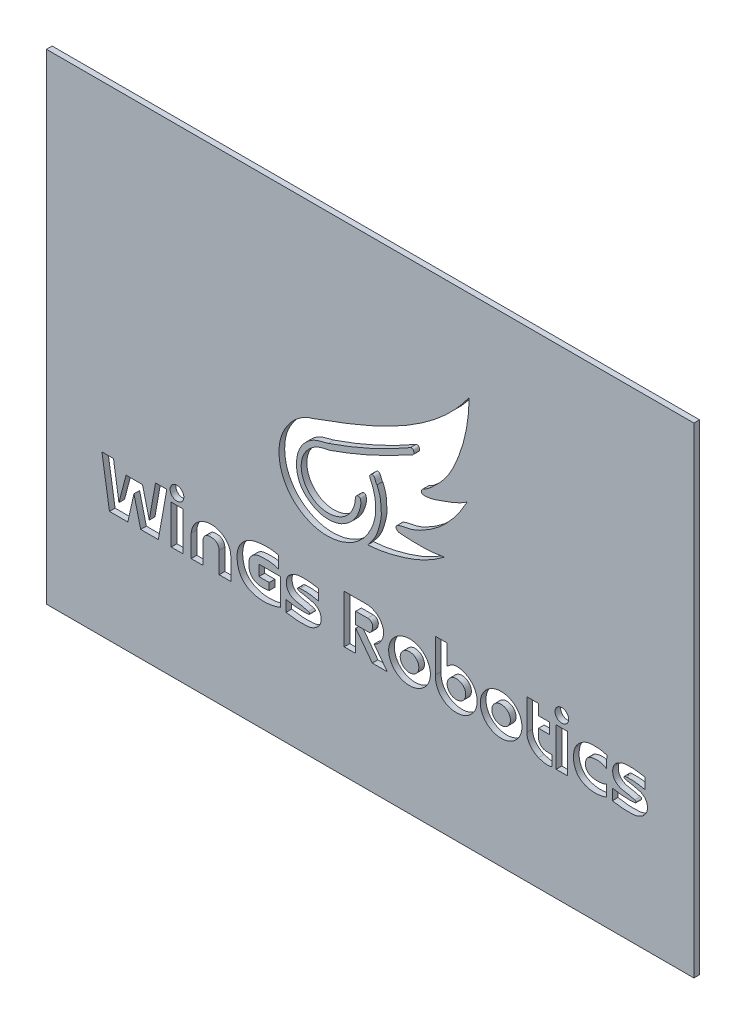
from build123d import *

# Parameters (mm, degrees)
SKETCH1_W           = 114.5
SKETCH1_H           = 85
BOSS_EXTRUDE1_DEPTH = 1
SKETCH2_W           = 2.050080953
SKETCH2_H           = 6.874434124
SKETCH2_R           = 1.213859124
SKETCH2_RX          = 3.688040456
SKETCH2_RY          = 3.586339088
SKETCH2_RX_2        = 1.645091786
SKETCH2_RY_2        = 1.613451305
SKETCH2_W_2         = 1.981029746
SKETCH2_H_2         = 6.809423223
SKETCH2_R_2         = 1.204225855
CUT_EXTRUDE1_DEPTH  = 11


with BuildPart() as part:
    # Sketch1 → Boss-Extrude1 (new body)
    with BuildSketch(Plane.XY):
        with Locations((57.25, 42.5)):
            Rectangle(SKETCH1_W, SKETCH1_H)
    extrude(amount=BOSS_EXTRUDE1_DEPTH)

    # Sketch2 → Cut-Extrude1 (cut)
    with BuildSketch(Plane.XY.offset(1)):
        with BuildLine():
            add(Edge.make_bspline(
                [(58.454232807, 47.516375152), (58.155201107, 47.766256761), (58.242612626, 48.405648514), (57.63435824, 48.725818852), (57.33951575, 48.561080563), (57.148056352, 48.331669293), (57.191833565, 47.968880637), (57.373109598, 47.594828313), (57.64633552, 47.047787141), (57.835821816, 46.438243828), (58.054855682, 45.66789616), (58.183227128, 44.904585404), (58.245836004, 43.851782874), (58.214820236, 42.740629424), (57.93171993, 41.583185887), (57.630830141, 40.625252894), (57.159571505, 39.759385244), (56.516222929, 38.60157538), (55.42470024, 37.436336943), (54.116750982, 36.463653396), (52.894350187, 35.923293203), (51.77243295, 35.514319825), (50.450751358, 35.31741506), (48.783731824, 35.237164884), (46.898690964, 35.69687239), (44.924093636, 36.617380122), (43.161708961, 38.106675964), (42.003804738, 39.901498444), (41.341001552, 41.702039563), (41.031458158, 43.795886426), (41.241639988, 46.031174435), (42.353202792, 48.424037338), (44.089054597, 50.650061335), (46.063860923, 51.731417101), (47.183080217, 52.026795225)],
                knots=[0, 0, 0, 0, 0.025484439, 0.03338283, 0.040232234, 0.046589479, 0.052344178, 0.063458754, 0.074883627, 0.093534169, 0.106469828, 0.129018368, 0.145624842, 0.177759685, 0.20359143, 0.225939601, 0.245354605, 0.270053463, 0.315285484, 0.351906237, 0.379454707, 0.405318365, 0.432327032, 0.469428533, 0.517419701, 0.561659463, 0.615846213, 0.670886596, 0.70401842, 0.744828345, 0.813276794, 0.851640065, 0.922150279, 1, 1, 1, 1], degree=3))
            add(Edge.make_bspline(
                [(47.183080217, 52.026795225), (57.216006345, 55.660419078), (68.349060224, 59.914176828), (74.752380083, 69.037208456)],
                knots=[0, 0, 0, 0, 1, 1, 1, 1], degree=3))
            add(Edge.make_bspline(
                [(74.752380083, 69.037208456), (74.736480386, 65.365885816), (73.727785029, 60.42570916), (70.966298428, 54.814242003), (68.758137434, 52.543762288), (67.300781423, 51.259360355), (66.385730313, 50.889179194), (66.191919274, 50.032187732), (67.340500179, 50.051911847), (68.580710142, 50.28254762), (71.142874018, 51.242375338), (73.213453076, 51.977233393), (74.434250991, 52.903399761)],
                knots=[0, 0, 0, 0, 0.360634108, 0.500005098, 0.614901621, 0.674581887, 0.691796307, 0.711226794, 0.738155757, 0.775635724, 0.851125952, 1, 1, 1, 1], degree=3))
            add(Edge.make_bspline(
                [(74.434250991, 52.903399761), (73.534437389, 51.244569181), (71.936292943, 48.870628445), (69.171720948, 46.226278325), (66.812856972, 44.685192365), (64.459018347, 43.563749511), (62.770947443, 43.441981971), (61.838513719, 43.010318867), (61.79284973, 42.33300121), (62.305978307, 42.117953901), (62.575531023, 42.134455593)],
                knots=[0, 0, 0, 0, 0.317486122, 0.477470025, 0.639062499, 0.792072541, 0.904921088, 0.928219039, 0.952009601, 1, 1, 1, 1], degree=3))
            add(Edge.make_bspline(
                [(62.575531023, 42.134455593), (63.354690243, 42.053803072), (64.7000675, 41.991387353), (66.708351282, 41.980958204), (68.546303226, 42.102590199), (69.809212082, 42.294223653), (70.410675427, 42.422660643)],
                knots=[0, 0, 0, 0, 0.298501271, 0.513417608, 0.765547662, 1, 1, 1, 1], degree=3))
            add(Edge.make_bspline(
                [(70.410675427, 42.422660643), (69.072158185, 41.392849447), (66.673523302, 39.95664783), (63.113718316, 38.677885822), (60.018889064, 37.859420378), (57.920946683, 37.5757846), (56.811430016, 37.503961117)],
                knots=[0, 0, 0, 0, 0.345508658, 0.567873889, 0.772356782, 1, 1, 1, 1], degree=3))
            add(Edge.make_bspline(
                [(56.811430016, 37.503961117), (57.150102419, 38.014022677), (57.987255556, 38.904490686), (58.613227549, 40.422973363), (59.012652401, 41.840922862), (59.290272897, 43.220897632), (59.160816631, 44.408188822), (59.11246086, 45.885792368), (58.773408264, 46.827837511), (58.454232807, 47.516375152)],
                knots=[0, 0, 0, 0, 0.1719112, 0.337536146, 0.453261138, 0.586013532, 0.727876697, 0.785410912, 1, 1, 1, 1], degree=3))
        make_face()
        with BuildLine():
            add(Edge.make_bspline(
                [(55.208034601, 44.116133089), (55.022625143, 44.179137333), (54.667036382, 43.958988589), (54.609396177, 43.464246826), (54.597765617, 42.863626491), (54.34232087, 42.009327553), (53.776372018, 40.734234474), (52.329674774, 39.33758596), (50.15244427, 38.721390022), (47.705197676, 39.133153699), (45.93028533, 40.62158031), (44.977495317, 42.793991738), (45.042833315, 45.537264714), (47.124443032, 48.008216113), (49.205962332, 48.468704925), (50.074487372, 48.612115737)],
                knots=[0, 0, 0, 0, 0.023492855, 0.044042325, 0.061062078, 0.101136052, 0.156797186, 0.239209866, 0.350065975, 0.433770548, 0.549578037, 0.629423488, 0.732521354, 0.886290578, 1, 1, 1, 1], degree=3))
            add(Edge.make_bspline(
                [(64.038603905, 54.882342772), (59.572034383, 52.406223373), (54.900103059, 50.294759316), (50.074487372, 48.612115737)],
                knots=[0, 0, 0, 0, 1, 1, 1, 1], degree=3))
            add(Edge.make_bspline(
                [(64.349924674, 56.161374818), (64.469308928, 56.198038689), (64.738228566, 56.247793356), (64.929809958, 55.987135025), (65.02677974, 55.728006959), (64.891079963, 55.148714005), (64.273965083, 55.054702659), (64.038603905, 54.882342772)],
                knots=[0, 0, 0, 0, 0.180534732, 0.288784375, 0.393192125, 0.542413532, 1, 1, 1, 1], degree=3))
            add(Edge.make_bspline(
                [(64.349924674, 56.161374818), (57.438497294, 52.157653387), (49.814342424, 49.548665095)],
                knots=[0, 0, 0, 1, 1, 1], degree=2))
            add(Edge.make_bspline(
                [(49.814342424, 49.548665095), (49.164290041, 49.378401155), (48.212436546, 49.196059818), (46.372347391, 48.377280304), (44.219210093, 46.16100786), (43.977382754, 42.604306322), (45.225353462, 40.052494882), (46.595117348, 38.914609571), (48.298977569, 37.990831076), (50.179012631, 37.837873079), (52.012731798, 38.232040281), (53.395544621, 39.100170897), (54.501661681, 40.189216921), (55.187854158, 41.482764429), (55.562081954, 42.679754198), (55.631497641, 43.576813671), (55.453855705, 44.128916533), (55.208034601, 44.116133089)],
                knots=[0, 0, 0, 0, 0.074166524, 0.105399841, 0.22059516, 0.394008221, 0.454413258, 0.527731026, 0.585288596, 0.665338457, 0.728527594, 0.788515133, 0.842168303, 0.897127647, 0.948286442, 0.97672011, 1, 1, 1, 1], degree=3))
        make_face(mode=Mode.SUBTRACT)
        Polygon((11.140293702, 19.790279863), (9.80265223, 28.23498876), (11.852733183, 28.23498876), (12.812345543, 21.968429251), (14.07728911, 26.810109799), (16.985205355, 26.810109799), (18.177451016, 21.968429251), (19.282459189, 28.23498876), (21.274381817, 28.23498876), (19.785291617, 19.790279863), (16.665334568, 19.790279863), (15.467765439, 24.653578889), (14.382620316, 19.790279863), align=None)
        with Locations((23.08455968, 23.227496925)):
            Rectangle(SKETCH2_W, SKETCH2_H)
        with Locations((23.077289889, 28.540319965)):
            Circle(SKETCH2_R)
        with BuildLine():
            add(Edge.make_bspline(
                [(30.550507488, 23.53425261), (30.543410322, 23.975896739), (30.106824896, 24.716492763), (29.076011424, 24.858477486), (28.007386667, 24.772266409), (27.672864704, 23.933055449), (27.642687936, 23.53425261)],
                knots=[0, 0, 0, 0, 0.311205264, 0.495487823, 0.702071237, 1, 1, 1, 1], degree=3))
            Line((27.642687936, 23.53425261), (27.642687936, 19.790279863))
            Line((27.642687936, 19.790279863), (25.597182949, 19.790279863))
            Line((25.597182949, 19.790279863), (25.597182949, 23.698574699))
            add(Edge.make_bspline(
                [(25.597182949, 23.698574699), (25.655024383, 24.365774688), (26.094095564, 25.511687071), (27.542408981, 26.573688518), (30.276837479, 27.206654041), (32.573603491, 25.561936036), (32.593329118, 23.698574699)],
                knots=[0, 0, 0, 0, 0.198571456, 0.340640158, 0.513500481, 1, 1, 1, 1], degree=3))
            Line((32.593329118, 23.698574699), (32.593329118, 19.790279863))
            Line((32.593329118, 19.790279863), (30.550507488, 19.790279863))
            Line((30.550507488, 19.790279863), (30.550507488, 23.53425261))
        make_face()
        with BuildLine():
            Line((39.392903947, 23.026010695), (39.392903947, 21.787154833))
            add(Edge.make_bspline(
                [(39.392903947, 21.787154833), (38.709328807, 21.648731932), (37.576908234, 21.542273573), (36.102464246, 22.345223797), (35.704866734, 23.743461009), (35.813146547, 25.200823073), (36.969778747, 26.203973561), (38.234458734, 26.273280017), (39.623410218, 26.318179205), (40.523608068, 26.087789356), (41.058476828, 25.902909309)],
                knots=[0, 0, 0, 0, 0.18146663, 0.284134985, 0.402884015, 0.534993454, 0.639880998, 0.765013074, 0.852735118, 1, 1, 1, 1], degree=3))
            Line((41.058476828, 25.902909309), (41.058476828, 28.008964275))
            add(Edge.make_bspline(
                [(41.058476828, 28.008964275), (40.053420622, 28.339513511), (38.252788176, 28.348289283), (35.579957653, 27.861823316), (33.807127389, 26.011782786), (33.590864529, 23.48949894), (34.259884703, 21.082821932), (36.595364, 19.679501372), (39.068594523, 19.5440089), (40.723497475, 19.936398387), (41.424471902, 20.231702472)],
                knots=[0, 0, 0, 0, 0.156695014, 0.267521344, 0.399378103, 0.502861963, 0.63762312, 0.747872283, 0.886034629, 1, 1, 1, 1], degree=3))
            Line((41.424471902, 20.231702472), (41.424471902, 24.925589684))
            Line((41.424471902, 24.925589684), (37.575915349, 24.925589684))
            Line((37.575915349, 24.925589684), (37.575915349, 23.026010695))
            Line((37.575915349, 23.026010695), (39.392903947, 23.026010695))
        make_face()
        with BuildLine():
            add(Edge.make_bspline(
                [(46.317322138, 22.049037935), (45.824731993, 22.210742689), (44.975778867, 22.40163227), (43.648132153, 22.55699702), (42.701652483, 23.251908996), (42.420499941, 24.163498462), (42.431107022, 24.854255388), (42.572538443, 25.490668332), (43.004076818, 26.004420138), (43.507908782, 26.358764483), (44.109433868, 26.601004045), (44.74426891, 26.734288086), (45.445562789, 26.743327695), (46.262343534, 26.742582693), (47.164011558, 26.592971419), (47.832474332, 26.519558956), (48.148216766, 26.428077311)],
                knots=[0, 0, 0, 0, 0.129354314, 0.216840147, 0.332807427, 0.395281765, 0.447955501, 0.504878839, 0.55358992, 0.611567985, 0.657300196, 0.714661081, 0.77238727, 0.832100329, 0.918345636, 1, 1, 1, 1], degree=3))
            Line((48.148216766, 26.428077311), (48.148216766, 24.517425483))
            add(Edge.make_bspline(
                [(48.148216766, 24.517425483), (46.54397318, 24.945679792), (44.888792958, 24.852708279)],
                knots=[0, 0, 0, 1, 1, 1], degree=2))
            add(Edge.make_bspline(
                [(44.888792958, 24.852708279), (44.689182117, 24.848786999), (44.51078328, 24.752820598)],
                knots=[0, 0, 0, 1, 1, 1], degree=2))
            add(Edge.make_bspline(
                [(44.51078328, 24.752820598), (44.406308103, 24.717681376), (44.387924492, 24.412408384), (44.702186936, 24.383832223), (44.806139371, 24.345586206)],
                knots=[0, 0, 0, 0, 0.400794389, 1, 1, 1, 1], degree=3))
            add(Edge.make_bspline(
                [(44.806139371, 24.345586206), (45.423564394, 24.273968664), (46.288006885, 24.064813555), (47.46290877, 23.806737598), (48.147012509, 23.319049527), (48.545595153, 22.590177306), (48.619598313, 21.763304801), (48.319682406, 20.806370209), (47.572161935, 20.139557196), (46.608821821, 19.710816999), (45.568962771, 19.681190723), (44.121341532, 19.640413074), (43.061307266, 19.870150262), (42.372568114, 19.942636104)],
                knots=[0, 0, 0, 0, 0.150365809, 0.21715787, 0.290606041, 0.346071454, 0.414260527, 0.486930119, 0.581715223, 0.647372918, 0.740088904, 0.830726665, 1, 1, 1, 1], degree=3))
            Line((42.372568114, 19.942636104), (42.372568114, 21.90410986))
            add(Edge.make_bspline(
                [(42.372568114, 21.90410986), (42.852483981, 21.803658023), (43.540520525, 21.684742464), (44.478218307, 21.597026122), (45.194509725, 21.588266366), (45.868754908, 21.582787144), (46.30052186, 21.631307616), (46.529651689, 21.687660928), (46.556676317, 21.797012759), (46.552265055, 21.96425316), (46.37902786, 22.020999474), (46.317322138, 22.049037935)],
                knots=[0, 0, 0, 0, 0.315552381, 0.449832635, 0.605449321, 0.778844328, 0.876434538, 0.897820479, 0.917220083, 0.942476197, 1, 1, 1, 1], degree=3))
        make_face()
        with BuildLine():
            add(Edge.make_bspline(
                [(56.993288194, 28.316464094), (57.507888583, 28.199947411), (58.406020002, 27.861332004), (59.304855599, 26.802490907), (59.764827962, 25.5392533), (59.345117638, 23.970677964), (58.578129601, 23.113462352), (57.950903995, 22.876918969)],
                knots=[0, 0, 0, 0, 0.21664701, 0.372499043, 0.551296922, 0.738033031, 1, 1, 1, 1], degree=3))
            Line((57.950903995, 22.876918969), (60.268122243, 19.79950217))
            Line((60.268122243, 19.79950217), (57.623356652, 19.79950217))
            Line((57.623356652, 19.79950217), (54.699102304, 23.683102457))
            Line((54.699102304, 23.683102457), (54.699102304, 19.79950217))
            Line((54.699102304, 19.79950217), (52.650010924, 19.79950217))
            Line((52.650010924, 19.79950217), (52.650010924, 28.316464094))
            Line((52.650010924, 28.316464094), (56.993288194, 28.316464094))
        make_face()
        with BuildLine():
            Line((56.811430016, 26.274566068), (54.699102304, 26.274566068))
            Line((54.699102304, 26.274566068), (54.699102304, 24.204529659))
            Line((54.699102304, 24.204529659), (56.894826652, 24.204529659))
            add(Edge.make_bspline(
                [(56.811430016, 26.274566068), (57.165142546, 26.312013915), (57.762696052, 25.857331641), (57.662984423, 24.819667856), (57.332468607, 24.193202864), (56.894826652, 24.204529659)],
                knots=[0, 0, 0, 0, 0.345185418, 0.626260613, 1, 1, 1, 1], degree=3))
        make_face(mode=Mode.SUBTRACT)
        with Locations(Location((64.208692975, 23.223770711), (0, 0, 180))):
            Ellipse(SKETCH2_RX, SKETCH2_RY)
        with Locations(Location((64.208692975, 23.223770711), (0, 0, -173.095653658))):
            Ellipse(SKETCH2_RX_2, SKETCH2_RY_2, mode=Mode.SUBTRACT)
        with BuildLine():
            Line((70.875700117, 29.486042678), (68.793403111, 29.486042678))
            Line((68.793403111, 29.486042678), (68.819382849, 23.63112519))
            add(Edge.make_bspline(
                [(68.819382849, 23.63112519), (67.662000297, 14.258830949), (74.941664532, 20.549874967), (82.00157216, 26.651006588), (72.525641569, 26.768570447)],
                knots=[6.176447512, 6.176447512, 6.176447512, 8.596254133, 8.596254133, 10.989752867, 10.989752867, 10.989752867], degree=2, weights=[1, 0.353109864, 1, 0.360142786, 0.986087077]))
            add(Edge.make_bspline(
                [(72.525641569, 26.768570447), (72.487865696, 26.769039116), (72.450088475, 26.768760138)],
                knots=[10.989752867, 10.989752867, 10.989752867, 11.016060754, 11.016060754, 11.016060754], degree=2, weights=[0.986087077, 0.992967077, 1]))
            add(Edge.make_bspline(
                [(70.875700117, 25.957189376), (71.166477188, 26.20926662), (71.655724283, 26.56346003), (72.234921297, 26.761658442), (72.450088475, 26.768760138)],
                knots=[0, 0, 0, 0, 0.616176335, 0.959930277, 0.959930277, 0.959930277, 0.959930277], degree=3))
            Line((70.875700117, 25.957189376), (70.875700117, 29.486042678))
        make_face()
        with BuildLine():
            add(Edge.make_bspline(
                [(70.875700117, 23.037387122), (71.211642535, 20.263073147), (73.493414254, 21.946870158), (75.775185973, 23.630667169), (73.157471836, 24.721184133), (70.539757699, 25.811701097), (70.875700117, 23.037387122)],
                knots=[0, 0, 0, 2.094395102, 2.094395102, 4.188790205, 4.188790205, 6.283185307, 6.283185307, 6.283185307], degree=2, weights=[1, 0.5, 1, 0.5, 1, 0.5, 1]))
        make_face(mode=Mode.SUBTRACT)
        with Locations(Location((80.411084057, 23.258188157), (0, 0, 180))):
            Ellipse(SKETCH2_RX, SKETCH2_RY)
        with Locations(Location((80.411084057, 23.258188157), (0, 0, -173.095653658))):
            Ellipse(SKETCH2_RX_2, SKETCH2_RY_2, mode=Mode.SUBTRACT)
        with BuildLine():
            Line((89.369700044, 19.790279863), (89.369700044, 21.656437237))
            add(Edge.make_bspline(
                [(89.369700044, 21.656437237), (88.886440556, 21.681452245), (88.103178845, 21.552378339), (87.281716916, 22.165179144), (87.087153612, 22.617862686), (87.019259344, 22.876918969)],
                knots=[0, 0, 0, 0, 0.514659913, 0.724878499, 1, 1, 1, 1], degree=3))
            Line((87.019259344, 22.876918969), (87.019259344, 24.517425483))
            Line((87.019259344, 24.517425483), (88.927403029, 24.517425483))
            Line((88.927403029, 24.517425483), (88.927403029, 26.428077311))
            Line((88.927403029, 26.428077311), (87.019259344, 26.428077311))
            Line((87.019259344, 26.428077311), (87.019259344, 28.316464094))
            Line((87.019259344, 28.316464094), (84.974819681, 28.316464094))
            Line((84.974819681, 28.316464094), (84.974819681, 22.876918969))
            add(Edge.make_bspline(
                [(84.974819681, 22.876918969), (84.904874023, 21.581617108), (85.880370875, 20.470748303), (87.019259344, 20.009497646)],
                knots=[0, 0, 0, 0, 1, 1, 1, 1], degree=3))
            add(Edge.make_bspline(
                [(87.019259344, 20.009497646), (87.764844995, 19.766104306), (88.592472755, 19.517741572), (89.369700044, 19.790279863)],
                knots=[0, 0, 0, 0, 1, 1, 1, 1], degree=3))
        make_face()
        with Locations((91.132775555, 23.194991475)):
            Rectangle(SKETCH2_W_2, SKETCH2_H_2)
        with Locations((91.149003897, 28.540319965)):
            Circle(SKETCH2_R_2)
        with BuildLine():
            add(Edge.make_bspline(
                [(99.107363386, 26.428077311), (99.045082433, 24.345586206)],
                knots=[0, 0, 1, 1], degree=1))
            add(Edge.make_bspline(
                [(99.045082433, 24.345586206), (98.140817478, 24.917670358), (96.933385238, 25.010368916), (95.962175283, 24.517425483)],
                knots=[0, 0, 0, 0, 1, 1, 1, 1], degree=3))
            add(Edge.make_bspline(
                [(95.962175283, 24.517425483), (95.590503523, 24.35964368), (95.371380246, 23.80674187), (95.284997638, 23.024137326), (95.465768646, 22.395754832), (95.907523378, 21.960247649), (96.471324165, 21.728931484), (97.52614725, 21.584707283), (98.434101144, 21.657237599), (99.045082433, 21.968429251)],
                knots=[0, 0, 0, 0, 0.178931515, 0.272004473, 0.383258516, 0.483726003, 0.563109197, 0.676720983, 1, 1, 1, 1], degree=3))
            add(Edge.make_bspline(
                [(99.045082433, 21.968429251), (99.076222909, 20.009497646)],
                knots=[0, 0, 1, 1], degree=1))
            add(Edge.make_bspline(
                [(99.107363386, 26.428077311), (98.706813514, 26.570619476), (98.057086859, 26.739047265), (97.144064108, 26.769744551), (96.425929948, 26.789005977), (95.6235266, 26.680118298), (94.766663587, 26.291049934), (94.018726516, 25.642257941), (93.394133402, 24.752120489), (93.19884016, 23.708895909), (93.18851624, 22.662055822), (93.450358204, 21.640092766), (94.692233145, 19.432342362), (97.670513165, 19.369727476), (99.076222909, 20.009497646)],
                knots=[0, 0, 0, 0, 0.080031766, 0.124597918, 0.17129882, 0.21488749, 0.275500126, 0.344981473, 0.39882164, 0.47645066, 0.539473476, 0.594476939, 0.673244535, 1, 1, 1, 1], degree=3))
        make_face()
        with BuildLine():
            add(Edge.make_bspline(
                [(104.02642021, 22.041632114), (103.533830066, 22.203336869), (102.68487694, 22.394226449), (101.357230225, 22.5495912), (100.410750556, 23.244503176), (100.129598013, 24.156092641), (100.140205094, 24.846849567), (100.281636516, 25.483262512), (100.71317489, 25.997014317), (101.217006854, 26.351358662), (101.81853194, 26.593598224), (102.453366982, 26.726882265), (103.154660861, 26.735921874), (103.971441607, 26.735176872), (104.87310963, 26.585565598), (105.541572404, 26.512153135), (105.857314838, 26.420671491)],
                knots=[0, 0, 0, 0, 0.129354314, 0.216840147, 0.332807427, 0.395281765, 0.447955501, 0.504878839, 0.55358992, 0.611567985, 0.657300196, 0.714661081, 0.77238727, 0.832100329, 0.918345636, 1, 1, 1, 1], degree=3))
            Line((105.857314838, 26.420671491), (105.857314838, 24.510019662))
            add(Edge.make_bspline(
                [(105.857314838, 24.510019662), (104.253071252, 24.938273972), (102.59789103, 24.845302458)],
                knots=[0, 0, 0, 1, 1, 1], degree=2))
            add(Edge.make_bspline(
                [(102.59789103, 24.845302458), (102.398280189, 24.841381178), (102.219881352, 24.745414777)],
                knots=[0, 0, 0, 1, 1, 1], degree=2))
            add(Edge.make_bspline(
                [(102.219881352, 24.745414777), (102.115406175, 24.710275556), (102.097022564, 24.405002563), (102.411285008, 24.376426403), (102.515237443, 24.338180385)],
                knots=[0, 0, 0, 0, 0.400794389, 1, 1, 1, 1], degree=3))
            add(Edge.make_bspline(
                [(102.515237443, 24.338180385), (103.132662467, 24.266562843), (103.997104957, 24.057407734), (105.172006842, 23.799331777), (105.856110582, 23.311643706), (106.254693225, 22.582771485), (106.328696385, 21.75589898), (106.028780479, 20.798964389), (105.281260008, 20.132151375), (104.317919893, 19.703411179), (103.278060843, 19.673784902), (101.830439604, 19.633007253), (100.770405338, 19.862744441), (100.081666186, 19.935230284)],
                knots=[0, 0, 0, 0, 0.150365809, 0.21715787, 0.290606041, 0.346071454, 0.414260527, 0.486930119, 0.581715223, 0.647372918, 0.740088904, 0.830726665, 1, 1, 1, 1], degree=3))
            Line((100.081666186, 19.935230284), (100.081666186, 21.89670404))
            add(Edge.make_bspline(
                [(100.081666186, 21.89670404), (100.561582053, 21.796252202), (101.249618597, 21.677336643), (102.18731638, 21.589620301), (102.903607798, 21.580860546), (103.57785298, 21.575381323), (104.009619933, 21.623901795), (104.238749761, 21.680255107), (104.265774389, 21.789606938), (104.261363127, 21.95684734), (104.088125932, 22.013593653), (104.02642021, 22.041632114)],
                knots=[0, 0, 0, 0, 0.315552381, 0.449832635, 0.605449321, 0.778844328, 0.876434538, 0.897820479, 0.917220083, 0.942476197, 1, 1, 1, 1], degree=3))
        make_face()
    extrude(amount=-CUT_EXTRUDE1_DEPTH, mode=Mode.SUBTRACT)


solid = part.part
